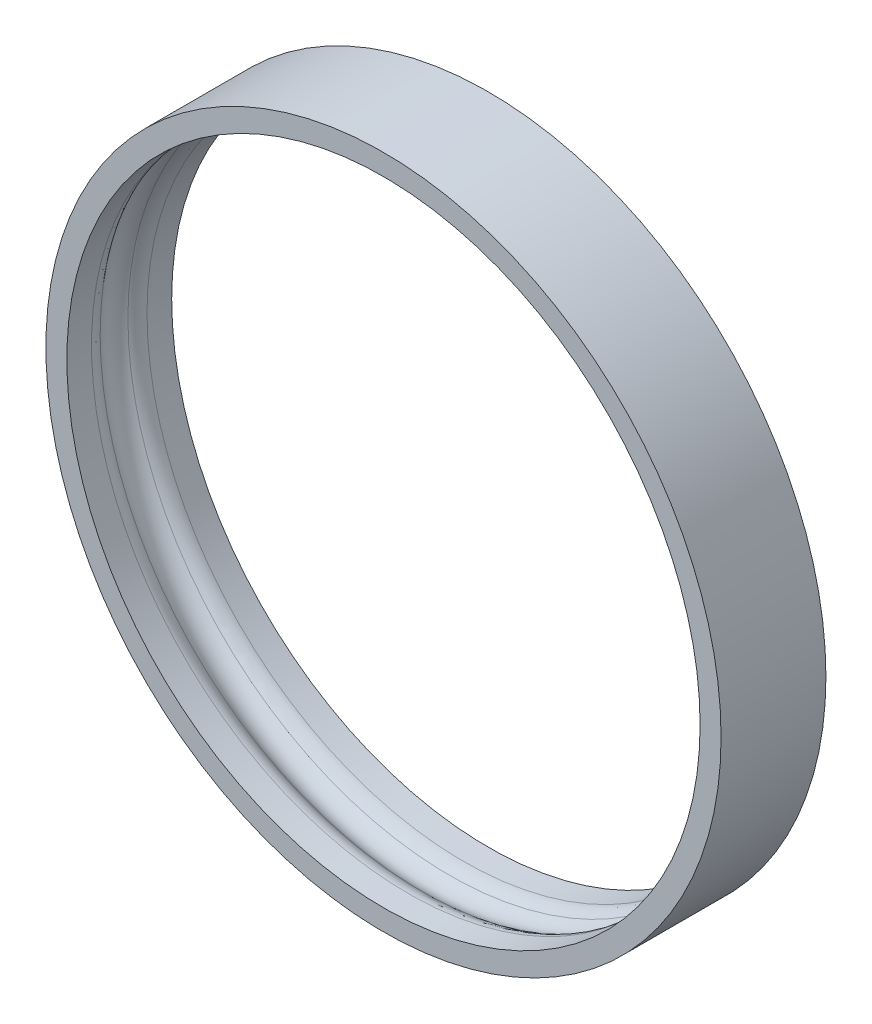
from build123d import *

# Parameters (mm, degrees)
SKETCH_1_R      = 16.1
SKETCH_1_R_2    = 15.1
EXTRUDE_1_DEPTH = 2.5
SKETCH_3_R      = 1
FILLET_1_R      = 1


with BuildPart() as part:
    # 草图1 → 凸台-拉伸1 (new body, symmetric)
    with BuildSketch(Plane.XY):
        Circle(SKETCH_1_R)
        Circle(SKETCH_1_R_2, mode=Mode.SUBTRACT)
    extrude(amount=EXTRUDE_1_DEPTH, both=True)

    # 草图3 → 切除-旋转1 (revolve, cut)
    with BuildSketch(Plane(origin=(0, 0, 0), x_dir=(1, 0, 0), z_dir=(0, 1, 0))):
        with Locations((-14.6, 0)):
            Circle(SKETCH_3_R)
    revolve(axis=Axis((0, 0, 2.5), (0, 0, -1)), mode=Mode.SUBTRACT)

    # 圆角1
    fillet_1_edges = [part.edges().sort_by_distance(p)[0] for p in [
        (0, 15.1, 0.866025404),
        (0, -15.1, -0.866025404),
    ]]
    fillet(fillet_1_edges, radius=FILLET_1_R)


solid = part.part
